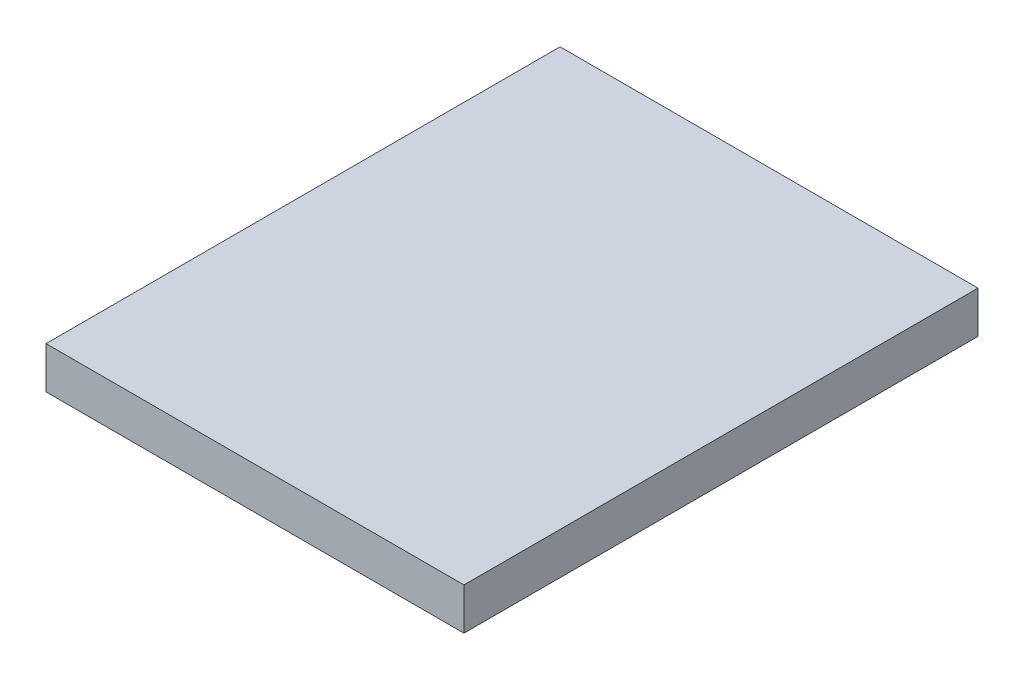
from build123d import *

# Parameters (mm, degrees)
SKETCH1_W           = 140
SKETCH1_H           = 12.3
BOSS_EXTRUDE1_DEPTH = 1
SKETCH2_W           = 12.3
SKETCH2_H           = 1
CUT_EXTRUDE1_DEPTH  = 130


with BuildPart() as part:
    # Sketch1 → Boss-Extrude1 (new body)
    with BuildSketch(Plane(origin=(0, 0, 0), x_dir=(1, 0, 0), z_dir=(0, 1, 0))):
        with Locations((70, 6.15)):
            Rectangle(SKETCH1_W, SKETCH1_H)
    extrude(amount=BOSS_EXTRUDE1_DEPTH)

    # Sketch2 → Cut-Extrude1 (cut)
    with BuildSketch(Plane.ZY):
        with Locations((-6.15, 0.5)):
            Rectangle(SKETCH2_W, SKETCH2_H)
    extrude(amount=-CUT_EXTRUDE1_DEPTH, mode=Mode.SUBTRACT)


solid = part.part
